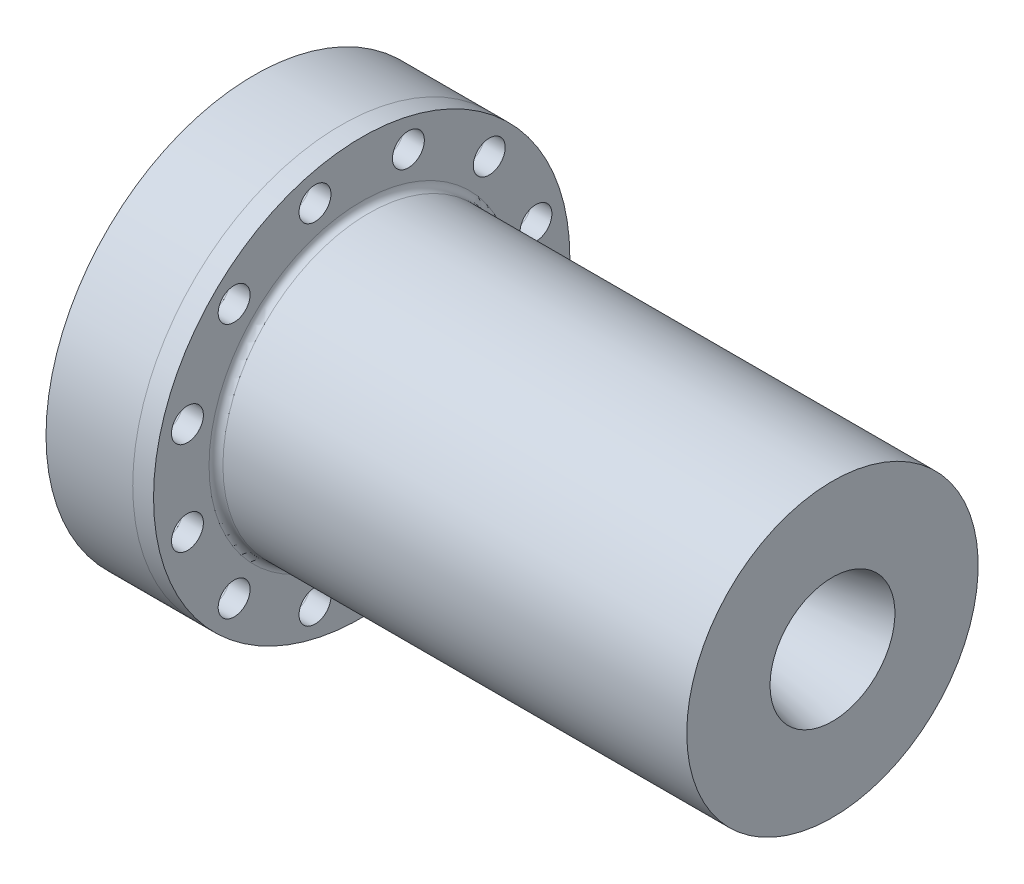
from build123d import *

# Parameters (mm, degrees)
FILLET1_R           = 1.27
SKETCH2_R           = 2.921
CUT_EXTRUDE1_DEPTH  = 3.81
CIRPATTERN1_COUNT   = 12
FILLET2_R           = 0.254
SKETCH4_R           = 38.1
BOSS_EXTRUDE1_DEPTH = 15.875
SKETCH5_R           = 2.921
CUT_EXTRUDE2_DEPTH  = 15.875
CIRPATTERN2_COUNT   = 12
SKETCH6_R           = 1.500000048
CUT_EXTRUDE3_DEPTH  = 15.875
CUT_EXTRUDE4_START  = -110.908183
SKETCH8_R           = 1.000000032
CUT_EXTRUDE4_DEPTH  = 122.726061


with BuildPart() as part:
    # Chamber Revolve → Revolve1 (revolve)
    with BuildSketch(Plane.XY):
        Polygon((3.81, 26.67), (89.984011525, 26.67), (89.984011525, 11.43), (71.85025, 7.57555), (60.3758, 19.05), (0, 19.05), (0, 23.114), (1.524, 23.114), (1.524, 25.654), (0, 25.654), (0, 38.1), (3.81, 38.1), align=None)
    revolve(axis=Axis((0, 0, 0), (1, 0, 0)))

    # Fillet1
    fillet1_edges = [part.edges().sort_by_distance(p)[0] for p in [
        (3.81, -26.67, 0),
    ]]
    fillet(fillet1_edges, radius=FILLET1_R)

    # Sketch2 → Cut-Extrude1 (cut)
    with BuildSketch(Plane.ZY):
        with Locations((-8.546204869, 31.894870784)):
            Circle(SKETCH2_R)
    cut_extrude1 = extrude(amount=-CUT_EXTRUDE1_DEPTH, mode=Mode.SUBTRACT)

    # CirPattern1: Cut-Extrude1 ×12 about axis
    cirpattern1_axis = Axis((0, 0, 0), (1, 0, 0))
    for i in range(1, CIRPATTERN1_COUNT):
        add(cut_extrude1.rotate(cirpattern1_axis, i * 360 / CIRPATTERN1_COUNT), mode=Mode.SUBTRACT)

    # Fillet2
    fillet2_edges = [part.edges().sort_by_distance(p)[0] for p in [
        (1.524, -23.114, 0),
        (1.524, -25.654, 0),
    ]]
    fillet(fillet2_edges, radius=FILLET2_R)


with BuildPart() as body_2:
    # Sketch4 → Boss-Extrude1 (new body)
    with BuildSketch(Plane.ZY):
        Circle(SKETCH4_R)
    extrude(amount=BOSS_EXTRUDE1_DEPTH)

    # Sketch5 → Cut-Extrude2 (cut)
    with BuildSketch(Plane(origin=(0, 0, 0), x_dir=(0, 0, -1), z_dir=(1, 0, 0))):
        with Locations((8.546204869, 31.894870784)):
            Circle(SKETCH5_R)
    cut_extrude2 = extrude(amount=-CUT_EXTRUDE2_DEPTH, mode=Mode.SUBTRACT)

    # CirPattern2: Cut-Extrude2 ×12 about axis
    cirpattern2_axis = Axis((0, 0, 0), (1, 0, 0))
    for i in range(1, CIRPATTERN2_COUNT):
        add(cut_extrude2.rotate(cirpattern2_axis, i * 360 / CIRPATTERN2_COUNT), mode=Mode.SUBTRACT)

    # Sketch6 → Cut-Extrude3 (cut)
    with BuildSketch(Plane.ZY.offset(15.875)):
        Circle(SKETCH6_R)
    extrude(amount=-CUT_EXTRUDE3_DEPTH, mode=Mode.SUBTRACT)

    # Sketch8 → Cut-Extrude4 (cut)
    with BuildSketch(Plane(origin=(-15.875, 19.714645835, 0), x_dir=(0.64278761, 0.766044443, 0), z_dir=(-0.766044443, 0.64278761, 0)).offset(CUT_EXTRUDE4_START)):
        Circle(SKETCH8_R)
    cut_extrude4 = extrude(amount=CUT_EXTRUDE4_DEPTH, mode=Mode.SUBTRACT)

    # Mirror1: Cut-Extrude4 across plane
    add(cut_extrude4.mirror(Plane.ZX), mode=Mode.SUBTRACT)

    # Sketch10 → 1_4 NPT Tapped Hole1 (revolve, cut)
    with BuildSketch(Plane(origin=(-15.875, 0, 0), x_dir=(0, 0, 1), z_dir=(0, 1, 0))):
        Polygon((0, 0), (0, 13.502347279), (5.5626, 10.16), (5.5626, 7.62), (5.952815843, 7.62), (6.1718317, 0.3051683), (6.477, 0), align=None)
    revolve(axis=Axis((-22.225, 0, 0), (1, 0, 0)), mode=Mode.SUBTRACT)

    # Sketch17 → 1_4 NPT Tapped Hole3 (revolve, cut)
    with BuildSketch(Plane(origin=(-25.743969021, 27.710959149, 0), x_dir=(-0.64278761, -0.766044443, 0), z_dir=(0, 0, 1))):
        Polygon((0, 0), (0, 25.4), (5.5626, 22.057652721), (5.5626, 20.32), (5.952833971, 20.32), (6.5520824, 0.3059176), (6.858, 0), align=None)
    revolve(axis=Axis((-30.608351235, 31.792660471, 0), (0.766044443, -0.64278761, 0)), mode=Mode.SUBTRACT)


solid = Compound([part.part, body_2.part])
